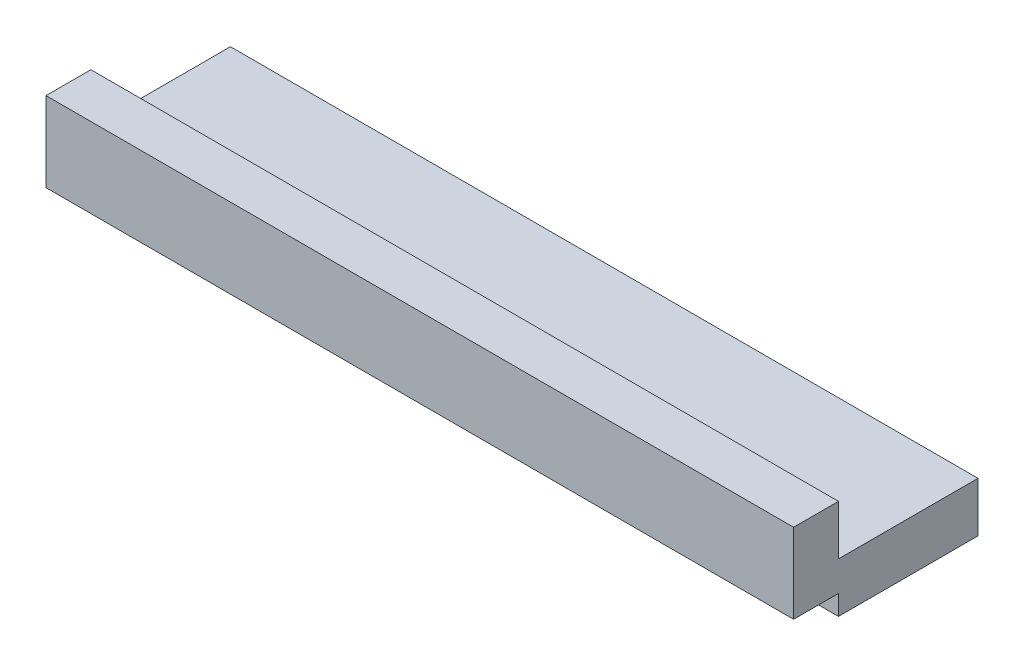
from build123d import *

# Parameters (mm, degrees)
SKETCH1_W           = 38.1
SKETCH1_H           = 2.286
BOSS_EXTRUDE1_DEPTH = 4.064
SKETCH3_W           = 38.1
SKETCH3_H           = 2.54
BOSS_EXTRUDE3_DEPTH = 7.112
SKETCH4_W           = 0.762
SKETCH4_H           = 1.016
CUT_EXTRUDE1_DEPTH  = 30.734


with BuildPart() as part:
    # Sketch1 → Boss-Extrude1 (new body)
    with BuildSketch(Plane(origin=(0, 0, 0), x_dir=(1, 0, 0), z_dir=(0, 1, 0))):
        with Locations((-8.736060606, 1.550939394)):
            Rectangle(SKETCH1_W, SKETCH1_H)
    extrude(amount=BOSS_EXTRUDE1_DEPTH)

    # Sketch3 → Boss-Extrude3 (add)
    with BuildSketch(Plane(origin=(0, 0, -2.693939394), x_dir=(-1, 0, 0), z_dir=(0, 0, -1))):
        with Locations((8.736060606, 0.254)):
            Rectangle(SKETCH3_W, SKETCH3_H)
    extrude(amount=BOSS_EXTRUDE3_DEPTH)

    # Sketch4 → Cut-Extrude1 (cut)
    with BuildSketch(Plane.ZY.offset(27.786060606)):
        with Locations((-3.074939394, -0.508)):
            Rectangle(SKETCH4_W, SKETCH4_H)
    extrude(amount=-CUT_EXTRUDE1_DEPTH, mode=Mode.SUBTRACT)


solid = part.part
